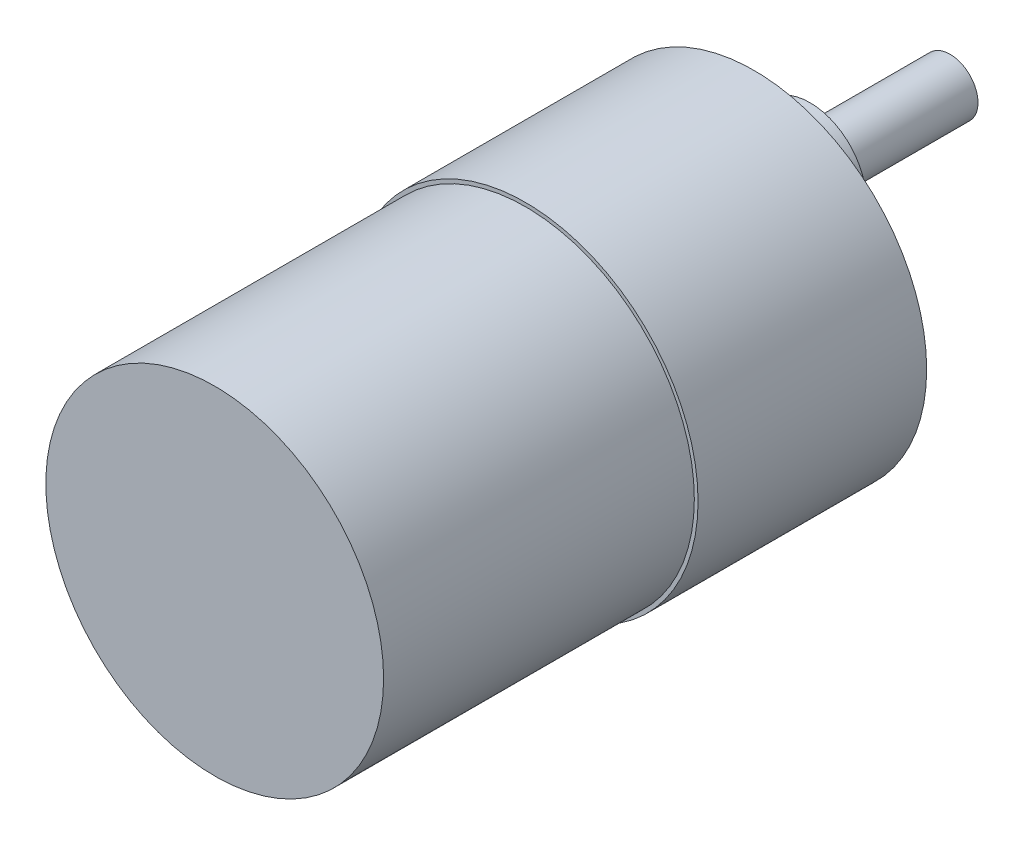
from build123d import *

# Parameters (mm, degrees)
SKETCH1_R           = 18.5
BOSS_EXTRUDE1_DEPTH = 24.5
SKETCH2_R           = 18.1
BOSS_EXTRUDE2_DEPTH = 33.3
SKETCH4_R           = 6
BOSS_EXTRUDE3_DEPTH = 6
SKETCH5_R           = 3
BOSS_EXTRUDE4_DEPTH = 15
CUT_EXTRUDE1_DEPTH  = 12
FACE_DIAMENTIONS_R  = 1.5
CUT_EXTRUDE3_DEPTH  = 3


with BuildPart() as part:
    # Sketch1 → Boss-Extrude1 (new body)
    with BuildSketch(Plane.XY):
        Circle(SKETCH1_R)
    extrude(amount=BOSS_EXTRUDE1_DEPTH)

    # Sketch2 → Boss-Extrude2 (add)
    with BuildSketch(Plane.XY.offset(24.5)):
        Circle(SKETCH2_R)
    extrude(amount=BOSS_EXTRUDE2_DEPTH)

    # Sketch4 → Boss-Extrude3 (add)
    with BuildSketch(Plane(origin=(0, 0, 0), x_dir=(-1, 0, 0), z_dir=(0, 0, -1))):
        with Locations((0, 6.5)):
            Circle(SKETCH4_R)
    extrude(amount=BOSS_EXTRUDE3_DEPTH)

    # Sketch5 → Boss-Extrude4 (add)
    with BuildSketch(Plane(origin=(0, 0, -6), x_dir=(-1, 0, 0), z_dir=(0, 0, -1))):
        with Locations((0, 6.5)):
            Circle(SKETCH5_R)
    extrude(amount=BOSS_EXTRUDE4_DEPTH)

    # Sketch6 → Cut-Extrude1 (cut)
    with BuildSketch(Plane(origin=(0, 0, -21), x_dir=(-1, 0, 0), z_dir=(0, 0, -1))):
        with BuildLine():
            Line((2.75, 6.5), (2.75, 5.301042119))
            ThreePointArc((2.75, 5.301042119), (3, 6.5), (2.75, 7.698957881))
            Line((2.75, 7.698957881), (2.75, 6.5))
        make_face()
    extrude(amount=-CUT_EXTRUDE1_DEPTH, mode=Mode.SUBTRACT)

    # face diamentions → Cut-Extrude3 (cut)
    with BuildSketch(Plane(origin=(0, 0, 0), x_dir=(-1, 0, 0), z_dir=(0, 0, -1))):
        with Locations((-16, 0)):
            Circle(FACE_DIAMENTIONS_R)
        with Locations((8, 13.856406461)):
            Circle(FACE_DIAMENTIONS_R)
        with Locations((8, -13.856406461)):
            Circle(FACE_DIAMENTIONS_R)
        with Locations((16, 0)):
            Circle(FACE_DIAMENTIONS_R)
        with Locations((-8, -13.856406461)):
            Circle(FACE_DIAMENTIONS_R)
        with Locations((-8, 13.856406461)):
            Circle(FACE_DIAMENTIONS_R)
    extrude(amount=-CUT_EXTRUDE3_DEPTH, mode=Mode.SUBTRACT)


solid = part.part
